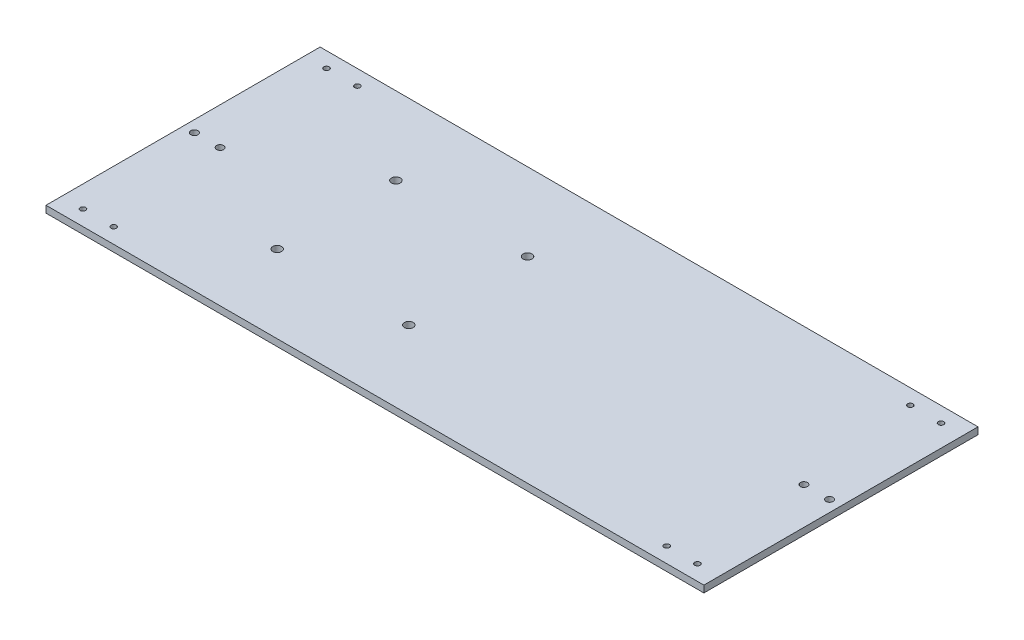
from build123d import *

# Parameters (mm, degrees)
SKETCH1_W           = 609.6
SKETCH1_H           = 254
SKETCH1_R           = 4.1
SKETCH1_R_2         = 2.5
SKETCH1_R_3         = 3.302
BOSS_EXTRUDE1_DEPTH = 6.35


with BuildPart() as part:
    # Sketch1 → Boss-Extrude1 (new body)
    with BuildSketch(Plane(origin=(0, 0, 0), x_dir=(1, 0, 0), z_dir=(0, 1, 0))):
        with Locations((304.8, 127)):
            Rectangle(SKETCH1_W, SKETCH1_H)
        with Locations((142.2, 72)):
            Circle(SKETCH1_R, mode=Mode.SUBTRACT)
        with Locations((142.2, 182)):
            Circle(SKETCH1_R, mode=Mode.SUBTRACT)
        with Locations((264.2, 182)):
            Circle(SKETCH1_R, mode=Mode.SUBTRACT)
        with Locations((264.2, 72)):
            Circle(SKETCH1_R, mode=Mode.SUBTRACT)
        with Locations((20.106234408, 14.145554392)):
            Circle(SKETCH1_R_2, mode=Mode.SUBTRACT)
        with Locations((48.606234408, 14.145554392)):
            Circle(SKETCH1_R_2, mode=Mode.SUBTRACT)
        with Locations((560.993765592, 14.145554392)):
            Circle(SKETCH1_R_2, mode=Mode.SUBTRACT)
        with Locations((589.493765592, 14.145554392)):
            Circle(SKETCH1_R_2, mode=Mode.SUBTRACT)
        with Locations((589.493765592, 239.854445608)):
            Circle(SKETCH1_R_2, mode=Mode.SUBTRACT)
        with Locations((560.993765592, 239.854445608)):
            Circle(SKETCH1_R_2, mode=Mode.SUBTRACT)
        with Locations((48.606234408, 239.854445608)):
            Circle(SKETCH1_R_2, mode=Mode.SUBTRACT)
        with Locations((20.106234408, 239.854445608)):
            Circle(SKETCH1_R_2, mode=Mode.SUBTRACT)
        with Locations((575.243765592, 127)):
            Circle(SKETCH1_R_3, mode=Mode.SUBTRACT)
        with Locations((599.056265592, 127)):
            Circle(SKETCH1_R_3, mode=Mode.SUBTRACT)
        with Locations((10.543734408, 127)):
            Circle(SKETCH1_R_3, mode=Mode.SUBTRACT)
        with Locations((34.356234408, 127)):
            Circle(SKETCH1_R_3, mode=Mode.SUBTRACT)
    extrude(amount=BOSS_EXTRUDE1_DEPTH)


solid = part.part
